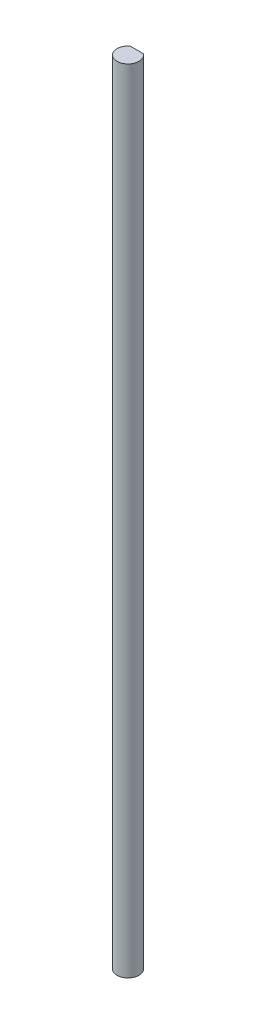
from build123d import *

# Parameters (mm, degrees)
BOSS_EXTRUDE1_DEPTH = 228.6


with BuildPart() as part:
    # Sketch1 → Boss-Extrude1 (new body)
    with BuildSketch(Plane(origin=(0, 0, 0), x_dir=(1, 0, 0), z_dir=(0, 1, 0))):
        with BuildLine():
            Line((-1.905, 2.54), (1.905, 2.54))
            ThreePointArc((1.905, 2.54), (0, -3.175), (-1.905, 2.54))
        make_face()
    extrude(amount=BOSS_EXTRUDE1_DEPTH)


solid = part.part
